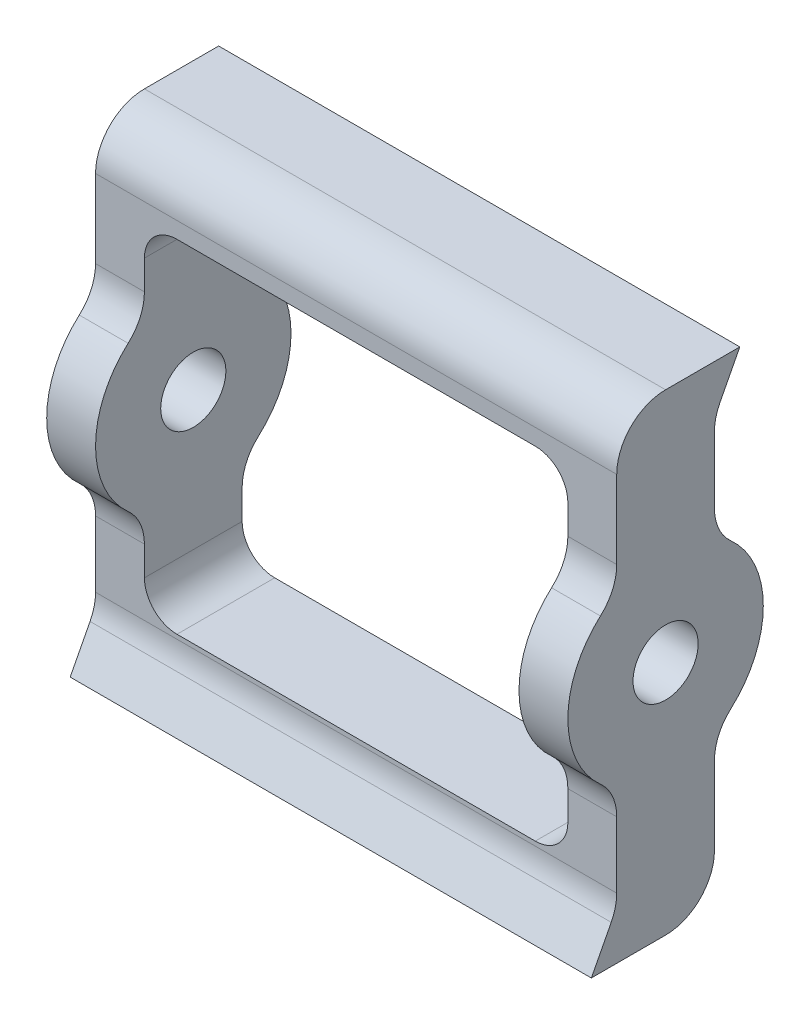
from build123d import *

# Parameters (mm, degrees)
SKETCH1_R               = 6.35
BOSS_EXTRUDE1_DEPTH     = 50.8
SKETCH2_W               = 82.55
SKETCH2_H               = 66.675
CUT_EXTRUDE1_DEPTH      = 20.05
CUT_EXTRUDE1_DEPTH_BACK = 20.05
FILLET1_R               = 6.35
FILLET2_R               = 9.525
FILLET3_R               = 9.525
FILLET4_R               = 9.525


with BuildPart() as part:
    # Sketch1 → Boss-Extrude1 (new body, symmetric)
    with BuildSketch(Plane(origin=(0, 0, 0), x_dir=(0, 0, -1), z_dir=(1, 0, 0))):
        with BuildLine():
            Line((9.525, 36.5125), (14.473290811, 46.0375))
            Line((14.473290811, 46.0375), (-9.525, 46.0375))
            Line((-9.525, 46.0375), (-9.525, 36.5125))
            Line((-9.525, 36.5125), (-9.525, 16.497783942))
            ThreePointArc((-9.525, 16.497783942), (-19.05, 0), (-9.525, -16.497783942))
            Line((-9.525, -16.497783942), (-9.525, -36.5125))
            Line((-9.525, -36.5125), (-14.473290811, -46.0375))
            Line((-14.473290811, -46.0375), (9.525, -46.0375))
            Line((9.525, -46.0375), (9.525, -36.5125))
            Line((9.525, -36.5125), (9.525, -16.497783942))
            ThreePointArc((9.525, -16.497783942), (19.05, 0), (9.525, 16.497783942))
            Line((9.525, 16.497783942), (9.525, 36.5125))
        make_face()
        Circle(SKETCH1_R, mode=Mode.SUBTRACT)
    extrude(amount=BOSS_EXTRUDE1_DEPTH, both=True)

    # Sketch2 → Cut-Extrude1 (cut, two sides)
    with BuildSketch(Plane.XY) as cut_extrude1_sk:
        Rectangle(SKETCH2_W, SKETCH2_H)
    extrude(amount=CUT_EXTRUDE1_DEPTH, mode=Mode.SUBTRACT)
    extrude(cut_extrude1_sk.sketch, amount=-CUT_EXTRUDE1_DEPTH_BACK, mode=Mode.SUBTRACT)

    # Fillet1
    fillet1_edges = [part.edges().sort_by_distance(p)[0] for p in [
        (-41.275, 33.3375, 0),
        (41.275, -33.3375, 0),
        (41.275, 33.3375, 0),
        (-41.275, -33.3375, 0),
    ]]
    fillet(fillet1_edges, radius=FILLET1_R)

    # Fillet2
    fillet2_edges = [part.edges().sort_by_distance(p)[0] for p in [
        (46.0375, 16.497783942, -9.525),
        (46.0375, -16.497783942, -9.525),
        (46.0375, -16.497783942, 9.525),
        (46.0375, 16.497783942, 9.525),
        (-46.0375, 16.497783942, -9.525),
        (-46.0375, -16.497783942, -9.525),
        (-46.0375, -16.497783942, 9.525),
        (-46.0375, 16.497783942, 9.525),
    ]]
    fillet(fillet2_edges, radius=FILLET2_R)

    # Fillet3
    fillet3_edges = [part.edges().sort_by_distance(p)[0] for p in [
        (0, -46.0375, -9.525),
        (0, 46.0375, 9.525),
    ]]
    fillet(fillet3_edges, radius=FILLET3_R)

    # Fillet4
    fillet4_edges = [part.edges().sort_by_distance(p)[0] for p in [
        (0, -36.5125, 9.525),
        (0, 36.5125, -9.525),
    ]]
    fillet(fillet4_edges, radius=FILLET4_R)


solid = part.part
